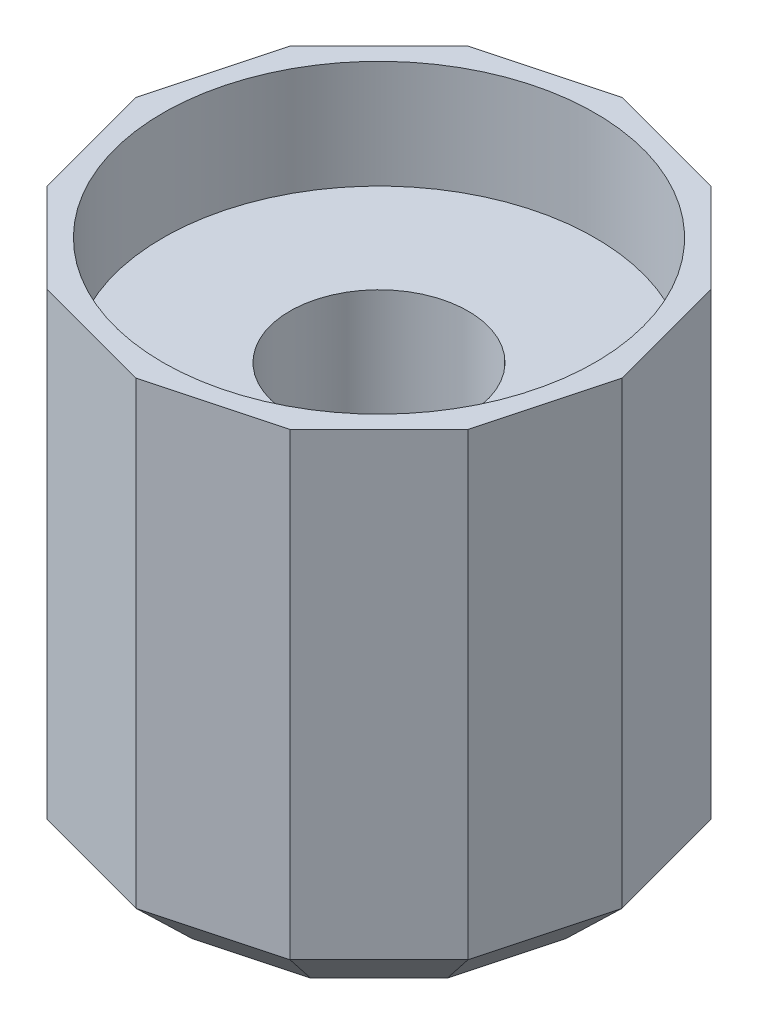
from build123d import *

# Parameters (mm, degrees)
BOSS_EXTRUDE1_DEPTH = 19
SKETCH2_R           = 8
CUT_EXTRUDE1_DEPTH  = 4
SKETCH3_R           = 3.3
CUT_EXTRUDE2_DEPTH  = 14
CHAMFER1_SIZE       = 2


with BuildPart() as part:
    # Sketch1 → Boss-Extrude1 (new body)
    with BuildSketch(Plane(origin=(0, 0, 0), x_dir=(1, 0, 0), z_dir=(0, 1, 0))):
        Polygon((0, 9), (-4.5, 7.794228634), (-7.794228634, 4.5), (-9, 0), (-7.794228634, -4.5), (-4.5, -7.794228634), (0, -9), (4.5, -7.794228634), (7.794228634, -4.5), (9, 0), (7.794228634, 4.5), (4.5, 7.794228634), align=None)
    extrude(amount=BOSS_EXTRUDE1_DEPTH)

    # Sketch2 → Cut-Extrude1 (cut)
    with BuildSketch(Plane(origin=(0, 19, 0), x_dir=(1, 0, 0), z_dir=(0, 1, 0))):
        Circle(SKETCH2_R)
    extrude(amount=-CUT_EXTRUDE1_DEPTH, mode=Mode.SUBTRACT)

    # Sketch3 → Cut-Extrude2 (cut)
    with BuildSketch(Plane(origin=(0, 15, 0), x_dir=(1, 0, 0), z_dir=(0, 1, 0))):
        Circle(SKETCH3_R)
    extrude(amount=-CUT_EXTRUDE2_DEPTH, mode=Mode.SUBTRACT)

    # Chamfer1
    chamfer1_edges = [part.edges().sort_by_distance(p)[0] for p in [
        (6.147114317, 0, -6.147114317),
        (8.397114317, 0, -2.25),
        (8.397114317, 0, 2.25),
        (6.147114317, 0, 6.147114317),
        (2.25, 0, 8.397114317),
        (-2.25, 0, 8.397114317),
        (-6.147114317, 0, 6.147114317),
        (-8.397114317, 0, 2.25),
        (-8.397114317, 0, -2.25),
        (-6.147114317, 0, -6.147114317),
        (-2.25, 0, -8.397114317),
        (2.25, 0, -8.397114317),
    ]]
    chamfer(chamfer1_edges, length=CHAMFER1_SIZE)


solid = part.part
